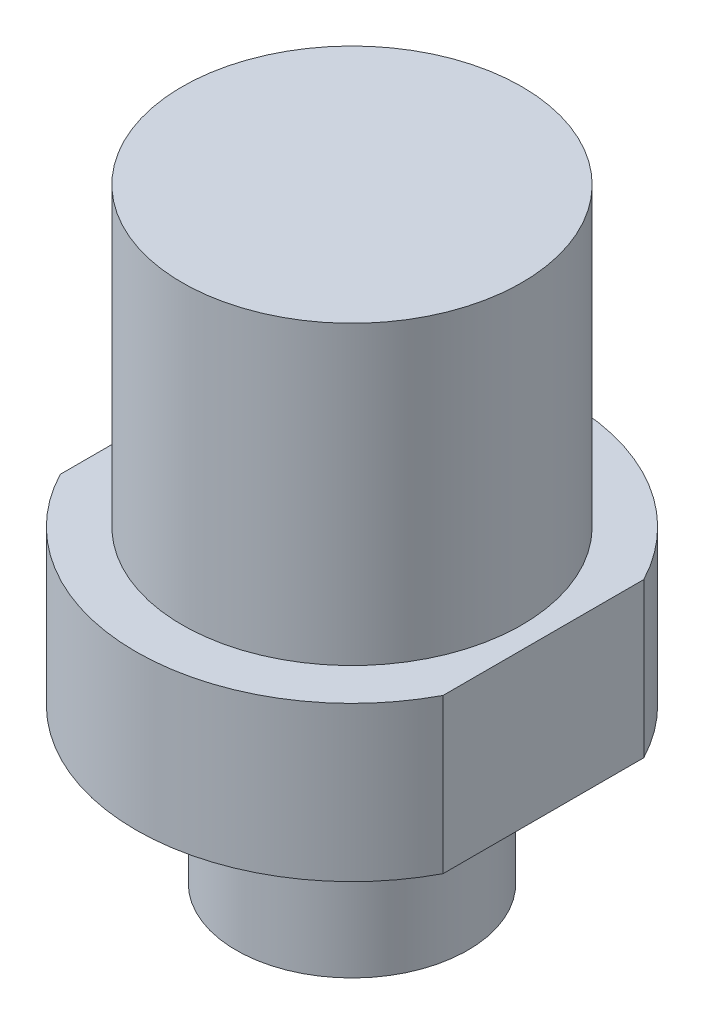
from build123d import *

# Parameters (mm, degrees)
CUT_EXTRUDE1_DEPTH = 25.892


with BuildPart() as part:
    # Sketch1 → Revolve1 (revolve)
    with BuildSketch(Plane(origin=(0, 0, 0), x_dir=(0, 0, -1), z_dir=(1, 0, 0))):
        Polygon((0, 0), (0, 18.542), (6.985, 18.542), (6.985, 6.35), (8.89, 6.35), (8.89, 0), (4.7625, 0), (4.7625, -6.35), (0, -6.35), align=None)
    revolve(axis=Axis((0, 0, 0), (0, 1, 0)))

    # Sketch2 → Cut-Extrude1 (cut, through all)
    with BuildSketch(Plane(origin=(0, 18.542, 0), x_dir=(1, 0, 0), z_dir=(0, 1, 0))):
        with BuildLine():
            Line((-7.874, -4.12701151), (-7.874, 4.12701151))
            ThreePointArc((-7.874, 4.12701151), (-8.89, 0), (-7.874, -4.12701151))
        make_face()
        with BuildLine():
            ThreePointArc((8.89, 0), (8.632263898, 2.125116467), (7.874, 4.12701151))
            Line((7.874, 4.12701151), (7.874, -4.12701151))
            ThreePointArc((7.874, -4.12701151), (8.632263898, -2.125116467), (8.89, 0))
        make_face()
    extrude(amount=-CUT_EXTRUDE1_DEPTH, mode=Mode.SUBTRACT)


solid = part.part
